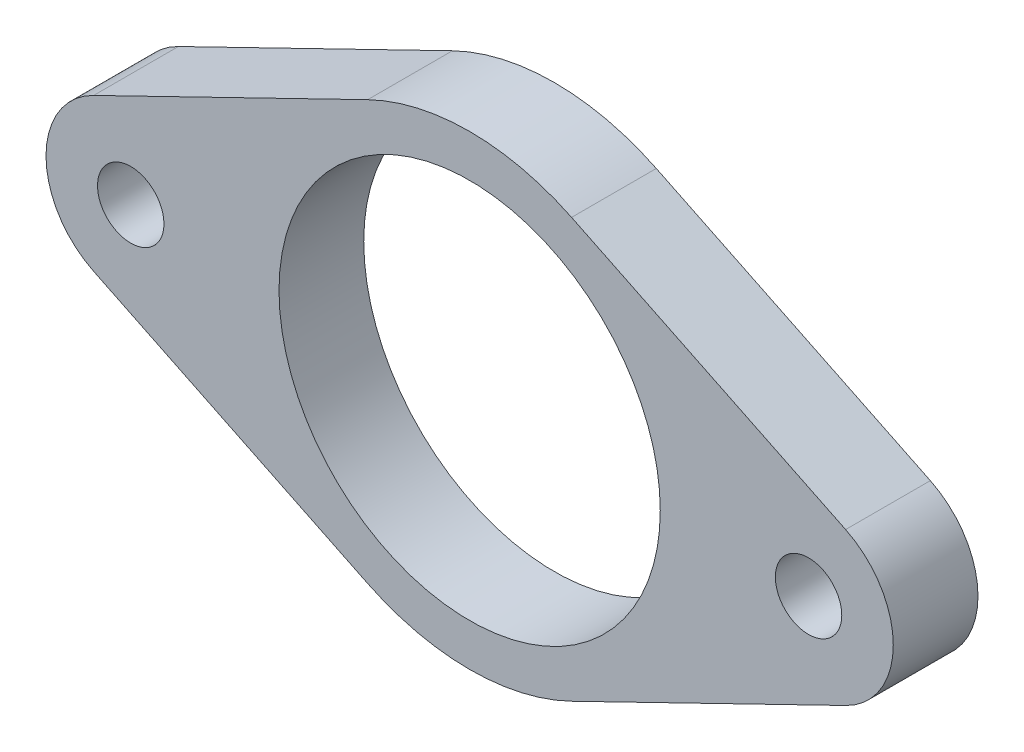
from build123d import *

# Parameters (mm, degrees)
SKETCH2_R           = 14.2875
SKETCH2_R_2         = 2.4892
BOSS_EXTRUDE1_DEPTH = 6.35


with BuildPart() as part:
    # Sketch2 → Boss-Extrude1 (new body)
    with BuildSketch(Plane.XY):
        with BuildLine():
            Line((7.63984375, 15.702601495), (28.178125, 5.710036907))
            ThreePointArc((28.178125, 5.710036907), (31.75, 0), (28.178125, -5.710036907))
            Line((28.178125, -5.710036907), (7.63984375, -15.702601495))
            ThreePointArc((7.63984375, -15.702601495), (0, -17.4625), (-7.63984375, -15.702601495))
            Line((-7.63984375, -15.702601495), (-28.178125, -5.710036907))
            ThreePointArc((-28.178125, -5.710036907), (-31.75, 0), (-28.178125, 5.710036907))
            Line((-28.178125, 5.710036907), (-7.63984375, 15.702601495))
            ThreePointArc((-7.63984375, 15.702601495), (0, 17.4625), (7.63984375, 15.702601495))
        make_face()
        Circle(SKETCH2_R, mode=Mode.SUBTRACT)
        with Locations((-25.4, 0)):
            Circle(SKETCH2_R_2, mode=Mode.SUBTRACT)
        with Locations((25.4, 0)):
            Circle(SKETCH2_R_2, mode=Mode.SUBTRACT)
    extrude(amount=BOSS_EXTRUDE1_DEPTH)


solid = part.part
